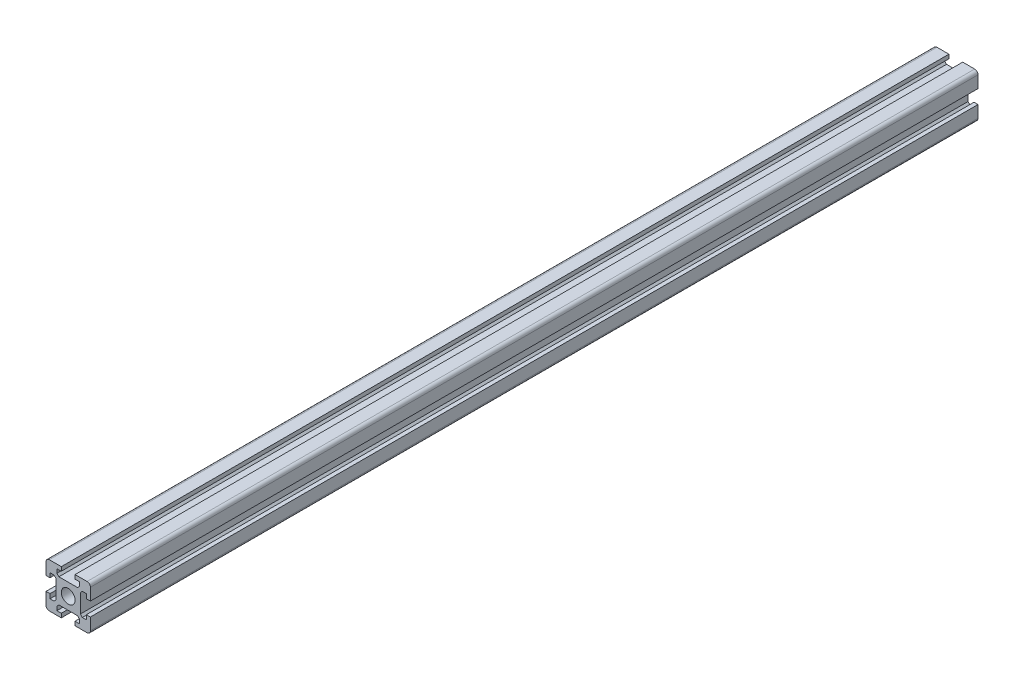
from build123d import *

# Parameters (mm, degrees)
SKETCH1_R           = 3.1
BOSS_EXTRUDE1_DEPTH = 400


with BuildPart() as part:
    # Sketch1 → Boss-Extrude1 (new body)
    with BuildSketch(Plane.XY):
        with BuildLine():
            Line((-10, 3.1), (-8.2, 3.1))
            Line((-8.2, 3.1), (-8.2, 5.1))
            Line((-8.2, 5.1), (-6.4, 5.1))
            Line((-6.4, 5.1), (-5.492892349, 4.192892349))
            Line((-5.492892349, 4.192892349), (-5.492892349, -4.192892349))
            Line((-5.492892349, -4.192892349), (-6.4, -5.1))
            Line((-6.4, -5.1), (-8.2, -5.1))
            Line((-8.2, -5.1), (-8.2, -3.1))
            Line((-8.2, -3.1), (-10, -3.1))
            Line((-10, -3.1), (-10, -8.5))
            ThreePointArc((-10, -8.5), (-9.560660172, -9.560660172), (-8.5, -10))
            Line((-8.5, -10), (-3.1, -10))
            Line((-3.1, -10), (-3.1, -8.2))
            Line((-3.1, -8.2), (-5.1, -8.2))
            Line((-5.1, -8.2), (-5.1, -6.4))
            Line((-5.1, -6.4), (-4.192892349, -5.492892349))
            Line((-4.192892349, -5.492892349), (4.192892349, -5.492892349))
            Line((4.192892349, -5.492892349), (5.1, -6.4))
            Line((5.1, -6.4), (5.1, -8.2))
            Line((5.1, -8.2), (3.1, -8.2))
            Line((3.1, -8.2), (3.1, -10))
            Line((3.1, -10), (8.5, -10))
            ThreePointArc((8.5, -10), (9.560660172, -9.560660172), (10, -8.5))
            Line((10, -8.5), (10, -3.1))
            Line((10, -3.1), (8.2, -3.1))
            Line((8.2, -3.1), (8.2, -5.1))
            Line((8.2, -5.1), (6.4, -5.1))
            Line((6.4, -5.1), (5.492892349, -4.192892349))
            Line((5.492892349, -4.192892349), (5.492892349, 4.192892349))
            Line((5.492892349, 4.192892349), (6.4, 5.1))
            Line((6.4, 5.1), (8.2, 5.1))
            Line((8.2, 5.1), (8.2, 3.1))
            Line((8.2, 3.1), (10, 3.1))
            Line((10, 3.1), (10, 8.5))
            ThreePointArc((10, 8.5), (9.560660172, 9.560660172), (8.5, 10))
            Line((8.5, 10), (3.1, 10))
            Line((3.1, 10), (3.1, 8.2))
            Line((3.1, 8.2), (5.1, 8.2))
            Line((5.1, 8.2), (5.1, 6.4))
            Line((5.1, 6.4), (4.192892349, 5.492892349))
            Line((4.192892349, 5.492892349), (-4.192892349, 5.492892349))
            Line((-4.192892349, 5.492892349), (-5.1, 6.4))
            Line((-5.1, 6.4), (-5.1, 8.2))
            Line((-5.1, 8.2), (-3.1, 8.2))
            Line((-3.1, 8.2), (-3.1, 10))
            Line((-3.1, 10), (-8.5, 10))
            ThreePointArc((-8.5, 10), (-9.560660172, 9.560660172), (-10, 8.5))
            Line((-10, 8.5), (-10, 3.1))
        make_face()
        Circle(SKETCH1_R, mode=Mode.SUBTRACT)
    extrude(amount=BOSS_EXTRUDE1_DEPTH)


solid = part.part
